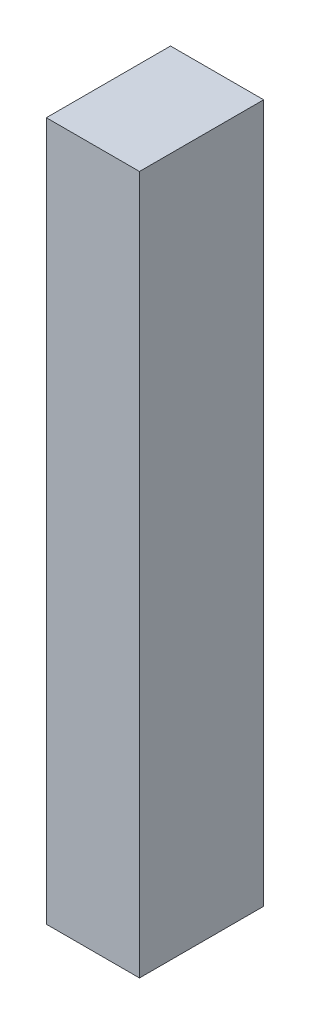
from build123d import *

# Parameters (mm, degrees)
SKETCH1_W           = 6
SKETCH1_H           = 8
BOSS_EXTRUDE1_DEPTH = 45


with BuildPart() as part:
    # Sketch1 → Boss-Extrude1 (new body)
    with BuildSketch(Plane(origin=(0, 0, 0), x_dir=(1, 0, 0), z_dir=(0, 1, 0))):
        Rectangle(SKETCH1_W, SKETCH1_H)
    extrude(amount=BOSS_EXTRUDE1_DEPTH)


solid = part.part
